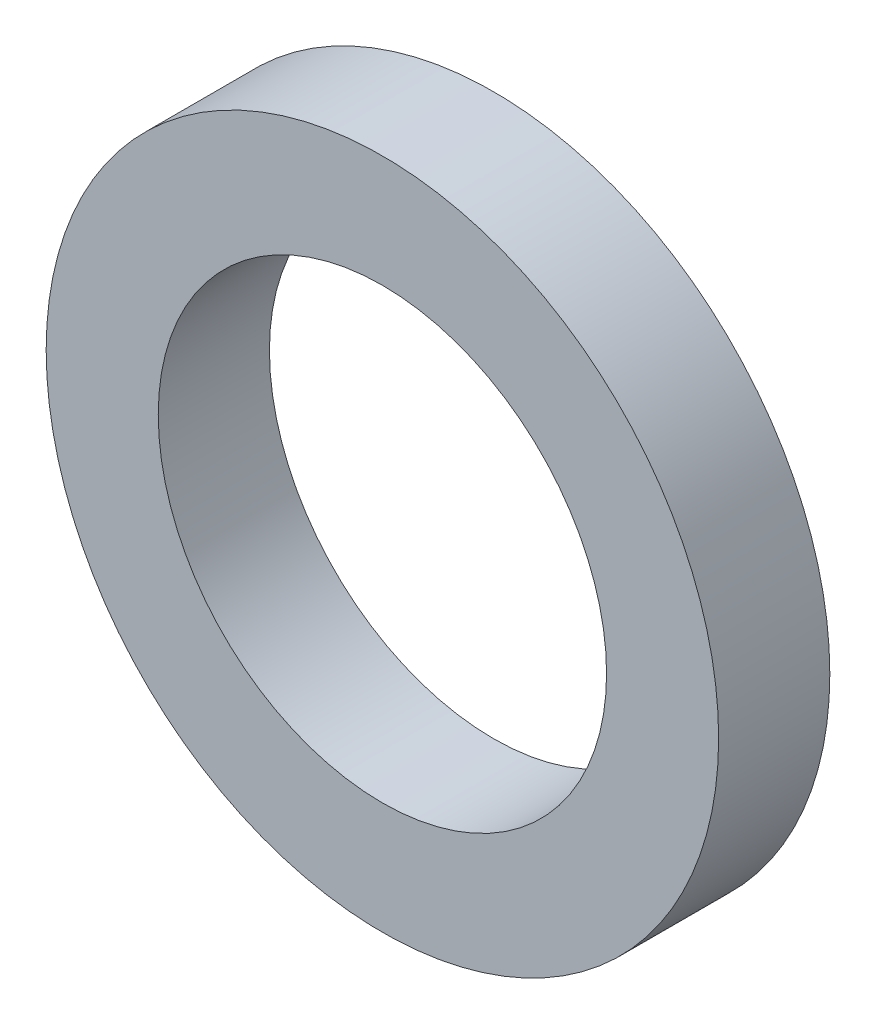
from build123d import *

# Parameters (mm, degrees)
SKETCH1_R           = 4.7625
SKETCH1_R_2         = 3.175
BOSS_EXTRUDE1_DEPTH = 1.5748


with BuildPart() as part:
    # Sketch1 → Boss-Extrude1 (new body)
    with BuildSketch(Plane.XY):
        Circle(SKETCH1_R)
        Circle(SKETCH1_R_2, mode=Mode.SUBTRACT)
    extrude(amount=BOSS_EXTRUDE1_DEPTH)


solid = part.part
